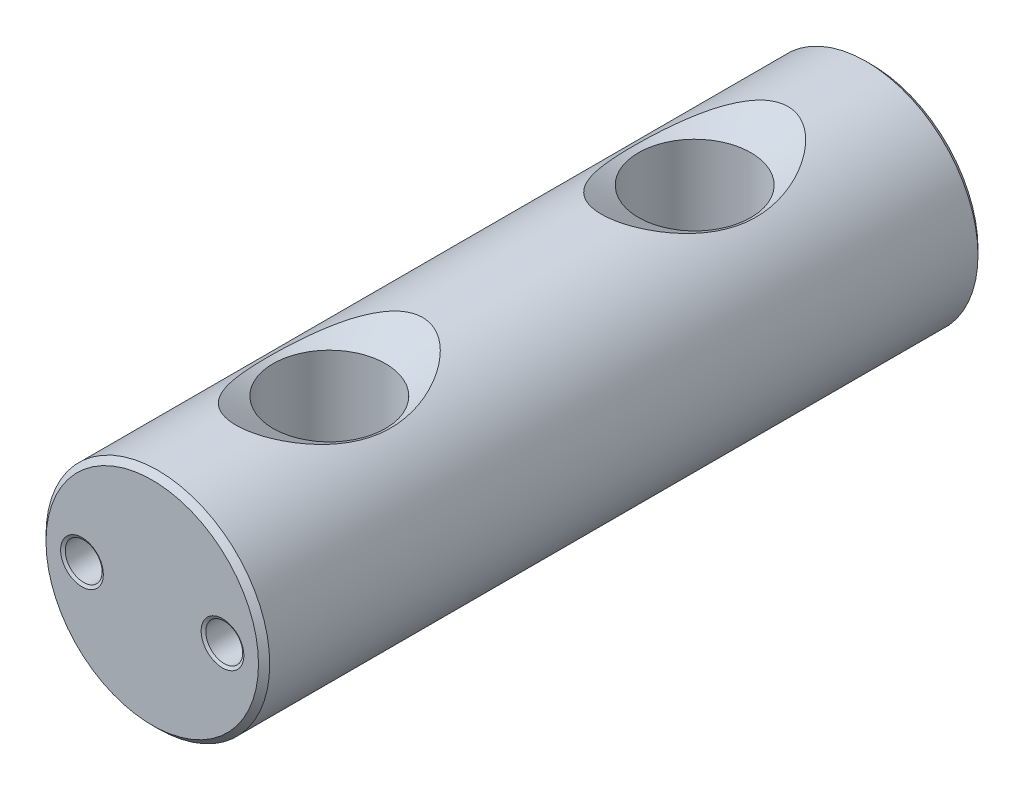
from build123d import *

# Parameters (mm, degrees)
SKETCH1_W                      = 81.28
SKETCH1_H                      = 12.6365
CHAMFER1_SIZE                  = 0.635
LPATTERN3_COUNT                = 2
LPATTERN3_PITCH                = 41.275
F_8_32_TAPPED_HOLE1_AT_2_COUNT = 2
F_8_32_TAPPED_HOLE1_AT_2_PITCH = 15.875


with BuildPart() as part:
    # Sketch1 → Base-Revolve (revolve)
    with BuildSketch(Plane(origin=(0, 0, 0), x_dir=(0, 0, -1), z_dir=(1, 0, 0)), mode=Mode.PRIVATE) as base_revolve_sk:
        with Locations((0, 6.31825)):
            Rectangle(SKETCH1_W, SKETCH1_H)
    revolve(base_revolve_sk.sketch.rotate(Axis((0, 0, 40.64), (0, 0, -1)), 90), axis=Axis((0, 0, 40.64), (0, 0, -1)))  # turned: the seam where the file's is

    # Chamfer1
    chamfer1_edges = [part.edges().sort_by_distance(p)[0] for p in [
        (-12.6365, 0, -40.64),
        (-12.6365, 0, 40.64),
    ]]
    chamfer(chamfer1_edges, length=CHAMFER1_SIZE)

    # Sketch17 → 1_2-13 Tapped Hole1 (revolve, cut)
    with BuildSketch(Plane(origin=(0, 12.6365, -20.6375), x_dir=(0, 0, 1), z_dir=(1, 0, 0))):
        Polygon((0, 0), (0, 25.273), (10.541, 25.273), (6.35, 22.853325022), (6.35, 2.419674978), (10.541, 0), align=None)
    f_1_2_13_tapped_hole1 = revolve(axis=Axis((0, 18.9865, -20.6375), (0, -1, 0)), mode=Mode.SUBTRACT)

    # LPattern3: 1_2-13 Tapped Hole1 ×2
    with Locations(*[(0, 0, i * LPATTERN3_PITCH) for i in range(1, LPATTERN3_COUNT)]):
        add(f_1_2_13_tapped_hole1, mode=Mode.SUBTRACT)

    # Sketch19 → 8-32 Tapped Hole1 (revolve, cut)
    with BuildSketch(Plane(origin=(7.9375, 0, 40.64), x_dir=(0, -1, 0), z_dir=(1, 0, 0))):
        Polygon((0, 0), (0, 9.927806461), (1.7272, 8.89), (1.7272, 5.08), (2.0828, 5.08), (2.0828, 0.190641059), (2.413, 0), align=None)
    f_8_32_tapped_hole1 = revolve(axis=Axis((7.9375, 0, 46.99), (0, 0, -1)), mode=Mode.SUBTRACT)

    # 8-32 Tapped Hole1 at 2: 8-32 Tapped Hole1 ×2
    with Locations(*[(-i * F_8_32_TAPPED_HOLE1_AT_2_PITCH, 0, 0) for i in range(1, F_8_32_TAPPED_HOLE1_AT_2_COUNT)]):
        add(f_8_32_tapped_hole1, mode=Mode.SUBTRACT)

    # Mirror1: 8-32 Tapped Hole1 across plane
    add(f_8_32_tapped_hole1.mirror(Plane.XY), mode=Mode.SUBTRACT)

    # Mirror1 copy 1 sketch → Mirror1 copy 1 (revolve, cut)
    with BuildSketch(Plane(origin=(-7.9375, 0, -40.64), x_dir=(0, -1, 0), z_dir=(1, 0, 0))):
        Polygon((0, 0), (0, -9.927806461), (1.7272, -8.89), (1.7272, -5.08), (2.0828, -5.08), (2.0828, -0.190641059), (2.413, 0), align=None)
    revolve(axis=Axis((-7.9375, 0, -46.99), (0, 0, -1)), mode=Mode.SUBTRACT)


solid = part.part
